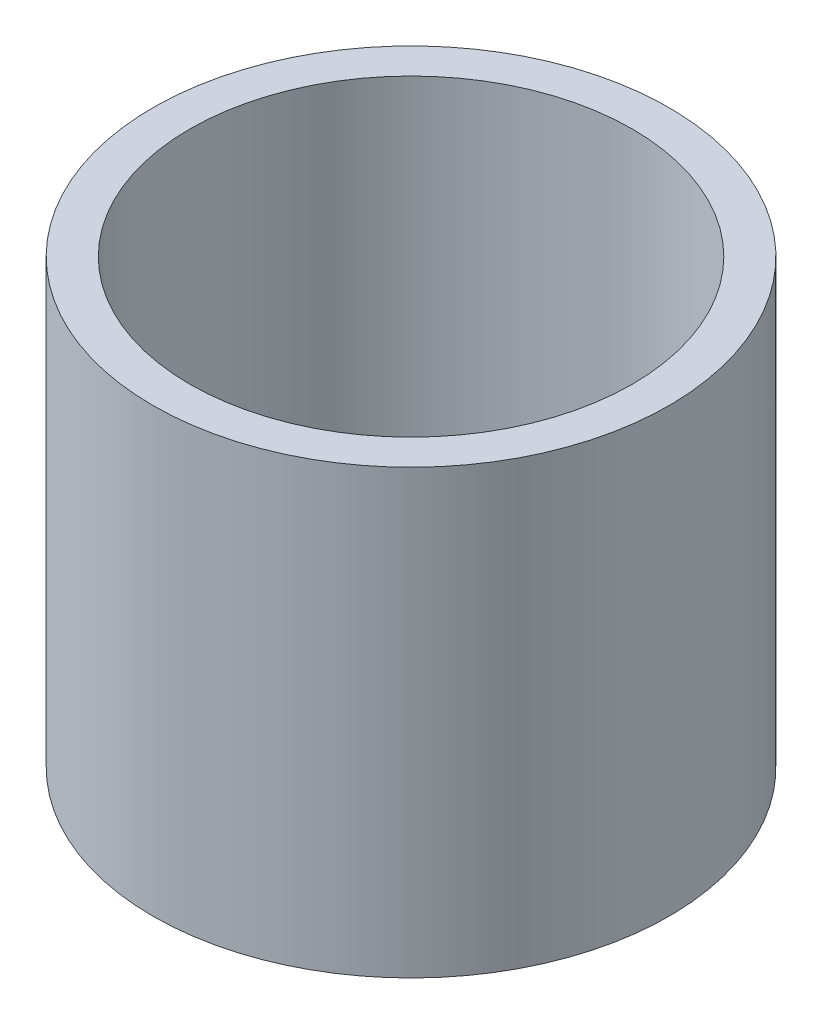
from build123d import *

# Parameters (mm, degrees)
SKETCH1_R           = 44.45
SKETCH1_R_2         = 38.1
BOSS_EXTRUDE1_DEPTH = 76.2


with BuildPart() as part:
    # Sketch1 → Boss-Extrude1 (new body)
    with BuildSketch(Plane(origin=(0, 0, 0), x_dir=(1, 0, 0), z_dir=(0, 1, 0))):
        Circle(SKETCH1_R)
        Circle(SKETCH1_R_2, mode=Mode.SUBTRACT)
    extrude(amount=BOSS_EXTRUDE1_DEPTH)


solid = part.part
